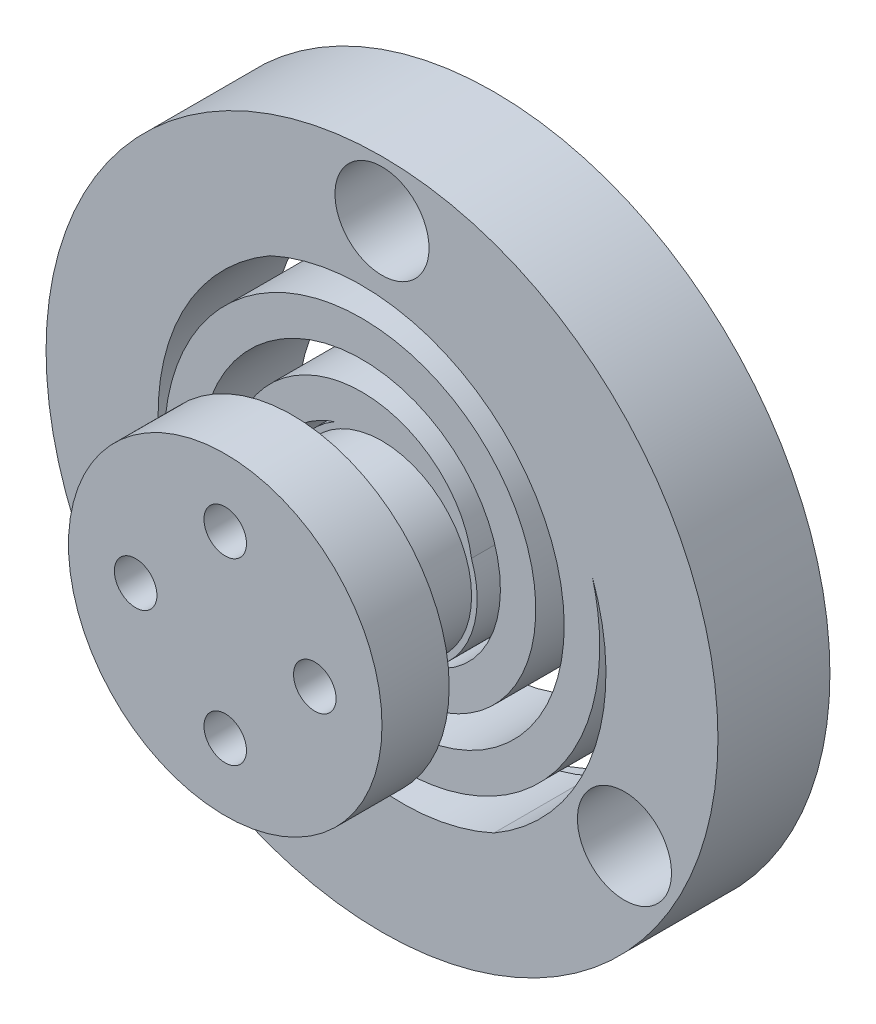
from build123d import *

# Parameters (mm, degrees)
SKETCH_1_R          = 15
SKETCH_1_R_2        = 10
SKETCH_1_R_3        = 1.2
EXTRUDE_1_DEPTH     = 1.4
SKETCH_2_R          = 15
SKETCH_2_R_2        = 10
SKETCH_2_R_3        = 2.1
EXTRUDE_2_DEPTH     = 3.6
EXTRUDE_3_DEPTH     = 4.4
SKETCH_9_R          = 3.25
CUT_EXTRUDE_1_DEPTH = 2.5
SKETCH_10_R         = 4
EXTRUDE_4_DEPTH     = 4
SKETCH_11_R         = 7
SKETCH_11_R_2       = 0.95
EXTRUDE_5_DEPTH     = 3


with BuildPart() as part:
    # Sketch 1 → Extrude 1 (new body)
    with BuildSketch(Plane.XY):
        Circle(SKETCH_1_R)
        Circle(SKETCH_1_R_2, mode=Mode.SUBTRACT)
        with Locations((0, 12.5)):
            Circle(SKETCH_1_R_3, mode=Mode.SUBTRACT)
        with Locations((10.825317547, -6.25)):
            Circle(SKETCH_1_R_3, mode=Mode.SUBTRACT)
        with Locations((-10.825317547, -6.25)):
            Circle(SKETCH_1_R_3, mode=Mode.SUBTRACT)
    extrude(amount=EXTRUDE_1_DEPTH)

    # Sketch 2 → Extrude 2 (add)
    with BuildSketch(Plane.XY.offset(1.4)):
        Circle(SKETCH_2_R)
        Circle(SKETCH_2_R_2, mode=Mode.SUBTRACT)
        with Locations((0, 12.5)):
            Circle(SKETCH_2_R_3, mode=Mode.SUBTRACT)
        with Locations((10.825317547, -6.25)):
            Circle(SKETCH_2_R_3, mode=Mode.SUBTRACT)
        with Locations((-10.825317547, -6.25)):
            Circle(SKETCH_2_R_3, mode=Mode.SUBTRACT)
    extrude(amount=EXTRUDE_2_DEPTH)

    # Sketch 8 → Extrude 3 (add)
    with BuildSketch(Plane.XY.offset(5)):
        with BuildLine():
            ThreePointArc((-2.125, 3.680607966), (-3.993693638, 1.453585609), (-3.993693638, -1.453585609))
            add(Edge.make_bspline(
                [(-9.396926208, -3.420201433), (-9.732062183, -2.149175506), (-9.806172611, -0.835010365), (-9.456725912, 1.676046677), (-9.033681598, 2.871966971), (-7.789656699, 4.972884513), (-6.969506065, 5.877213907), (-5.085556702, 7.278578571), (-4.022753032, 7.775339442), (-1.834341922, 8.316896689), (-0.709724019, 8.361833006), (1.425354593, 8.02880188), (2.434991624, 7.65134079), (4.194832357, 6.566362619), (4.944502403, 5.859612911), (6.091617732, 4.253128009), (6.488888652, 3.354278704), (6.901731194, 1.519508339), (6.917493401, 0.584437672), (6.600877847, -1.174662508), (6.268999982, -1.998016278), (5.34306854, -3.416780201), (4.749719757, -4.011790899), (3.420699316, -4.904656893), (2.685804375, -5.202437862), (1.204674755, -5.486565699), (0.459151326, -5.473153796), (-0.923970423, -5.172953815), (-1.561040931, -4.886659174), (-2.638728045, -4.11977446), (-3.079079395, -3.639826603), (-3.717696054, -2.588270623), (-3.915987072, -2.017330047), (-3.993693638, -1.453585609)],
                knots=[0, 0, 0, 0, 0.0625, 0.0625, 0.125, 0.125, 0.1875, 0.1875, 0.25, 0.25, 0.3125, 0.3125, 0.375, 0.375, 0.4375, 0.4375, 0.5, 0.5, 0.5625, 0.5625, 0.625, 0.625, 0.6875, 0.6875, 0.75, 0.75, 0.8125, 0.8125, 0.875, 0.875, 0.9375, 0.9375, 1, 1, 1, 1], degree=3))
            ThreePointArc((-9.396926208, -3.420201433), (-3.420201433, -9.396926208), (5, -8.660254038))
            add(Edge.make_bspline(
                [(5, -8.660254038), (3.806479564, -9.211009881), (2.525148685, -9.512196786), (-0.008440541, -9.604099447), (-1.259652992, -9.395151506), (-3.544675532, -8.534846644), (-4.577683795, -7.884191092), (-6.284902954, -6.272207574), (-6.958670832, -5.311811899), (-7.872014208, -3.250688101), (-8.111555691, -2.150958779), (-8.154336566, 0.009513438), (-7.957931589, 1.069357245), (-7.195029811, 2.990866525), (-6.629196056, 3.851873198), (-5.246311756, 5.260524443), (-4.430103363, 5.807843469), (-2.694896637, 6.533018535), (-1.776768874, 6.710914596), (0.010586336, 6.704573685), (0.879061498, 6.520711671), (2.437057517, 5.855212978), (3.126062601, 5.37420102), (4.236145931, 4.220415939), (4.657016106, 3.548394826), (5.194022862, 2.139105174), (5.310273501, 1.402578969), (5.254810803, -0.011659233), (5.083491754, -0.688765751), (4.515396145, -1.883248509), (4.119205984, -2.400252004), (3.194520122, -3.21176742), (2.666686289, -3.506188743), (2.125, -3.680607966)],
                knots=[0, 0, 0, 0, 0.0625, 0.0625, 0.125, 0.125, 0.1875, 0.1875, 0.25, 0.25, 0.3125, 0.3125, 0.375, 0.375, 0.4375, 0.4375, 0.5, 0.5, 0.5625, 0.5625, 0.625, 0.625, 0.6875, 0.6875, 0.75, 0.75, 0.8125, 0.8125, 0.875, 0.875, 0.9375, 0.9375, 1, 1, 1, 1], degree=3))
            ThreePointArc((2.125, -3.680607966), (3.993693638, -1.453585609), (3.993693638, 1.453585609))
            add(Edge.make_bspline(
                [(9.396926208, 3.420201433), (9.732062183, 2.149175506), (9.806172611, 0.835010365), (9.456725912, -1.676046677), (9.033681598, -2.871966971), (7.789656699, -4.972884513), (6.969506065, -5.877213907), (5.085556702, -7.278578571), (4.022753032, -7.775339442), (1.834341922, -8.316896689), (0.709724019, -8.361833006), (-1.425354593, -8.02880188), (-2.434991624, -7.65134079), (-4.194832357, -6.566362619), (-4.944502403, -5.859612911), (-6.091617732, -4.253128009), (-6.488888652, -3.354278704), (-6.901731194, -1.519508339), (-6.917493401, -0.584437672), (-6.600877847, 1.174662508), (-6.268999982, 1.998016278), (-5.34306854, 3.416780201), (-4.749719757, 4.011790899), (-3.420699316, 4.904656893), (-2.685804375, 5.202437862), (-1.204674755, 5.486565699), (-0.459151326, 5.473153796), (0.923970423, 5.172953815), (1.561040931, 4.886659174), (2.638728045, 4.11977446), (3.079079395, 3.639826603), (3.717696054, 2.588270623), (3.915987072, 2.017330047), (3.993693638, 1.453585609)],
                knots=[0, 0, 0, 0, 0.0625, 0.0625, 0.125, 0.125, 0.1875, 0.1875, 0.25, 0.25, 0.3125, 0.3125, 0.375, 0.375, 0.4375, 0.4375, 0.5, 0.5, 0.5625, 0.5625, 0.625, 0.625, 0.6875, 0.6875, 0.75, 0.75, 0.8125, 0.8125, 0.875, 0.875, 0.9375, 0.9375, 1, 1, 1, 1], degree=3))
            ThreePointArc((9.396926208, 3.420201433), (3.420201433, 9.396926208), (-5, 8.660254038))
            add(Edge.make_bspline(
                [(-5, 8.660254038), (-3.806479564, 9.211009881), (-2.525148685, 9.512196786), (0.008440541, 9.604099447), (1.259652992, 9.395151506), (3.544675532, 8.534846644), (4.577683795, 7.884191092), (6.284902954, 6.272207574), (6.958670832, 5.311811899), (7.872014208, 3.250688101), (8.111555691, 2.150958779), (8.154336566, -0.009513438), (7.957931589, -1.069357245), (7.195029811, -2.990866525), (6.629196056, -3.851873198), (5.246311756, -5.260524443), (4.430103363, -5.807843469), (2.694896637, -6.533018535), (1.776768874, -6.710914596), (-0.010586336, -6.704573685), (-0.879061498, -6.520711671), (-2.437057517, -5.855212978), (-3.126062601, -5.37420102), (-4.236145931, -4.220415939), (-4.657016106, -3.548394826), (-5.194022862, -2.139105174), (-5.310273501, -1.402578969), (-5.254810803, 0.011659233), (-5.083491754, 0.688765751), (-4.515396145, 1.883248509), (-4.119205984, 2.400252004), (-3.194520122, 3.21176742), (-2.666686289, 3.506188743), (-2.125, 3.680607966)],
                knots=[0, 0, 0, 0, 0.0625, 0.0625, 0.125, 0.125, 0.1875, 0.1875, 0.25, 0.25, 0.3125, 0.3125, 0.375, 0.375, 0.4375, 0.4375, 0.5, 0.5, 0.5625, 0.5625, 0.625, 0.625, 0.6875, 0.6875, 0.75, 0.75, 0.8125, 0.8125, 0.875, 0.875, 0.9375, 0.9375, 1, 1, 1, 1], degree=3))
        make_face()
    extrude(amount=-EXTRUDE_3_DEPTH)

    # Sketch 9 → Cut-Extrude 1 (cut)
    with BuildSketch(Plane(origin=(0, 0, 0.6), x_dir=(-1, 0, 0), z_dir=(0, 0, -1))):
        Circle(SKETCH_9_R)
    extrude(amount=-CUT_EXTRUDE_1_DEPTH, mode=Mode.SUBTRACT)

    # Sketch 10 → Extrude 4 (add)
    with BuildSketch(Plane.XY.offset(5)):
        Circle(SKETCH_10_R)
    extrude(amount=EXTRUDE_4_DEPTH)

    # Sketch 11 → Extrude 5 (add)
    with BuildSketch(Plane.XY.offset(9)):
        Circle(SKETCH_11_R)
        with Locations((0, 4)):
            Circle(SKETCH_11_R_2, mode=Mode.SUBTRACT)
        with Locations((4, 0)):
            Circle(SKETCH_11_R_2, mode=Mode.SUBTRACT)
        with Locations((0, -4)):
            Circle(SKETCH_11_R_2, mode=Mode.SUBTRACT)
        with Locations((-4, 0)):
            Circle(SKETCH_11_R_2, mode=Mode.SUBTRACT)
    extrude(amount=EXTRUDE_5_DEPTH)


solid = part.part
